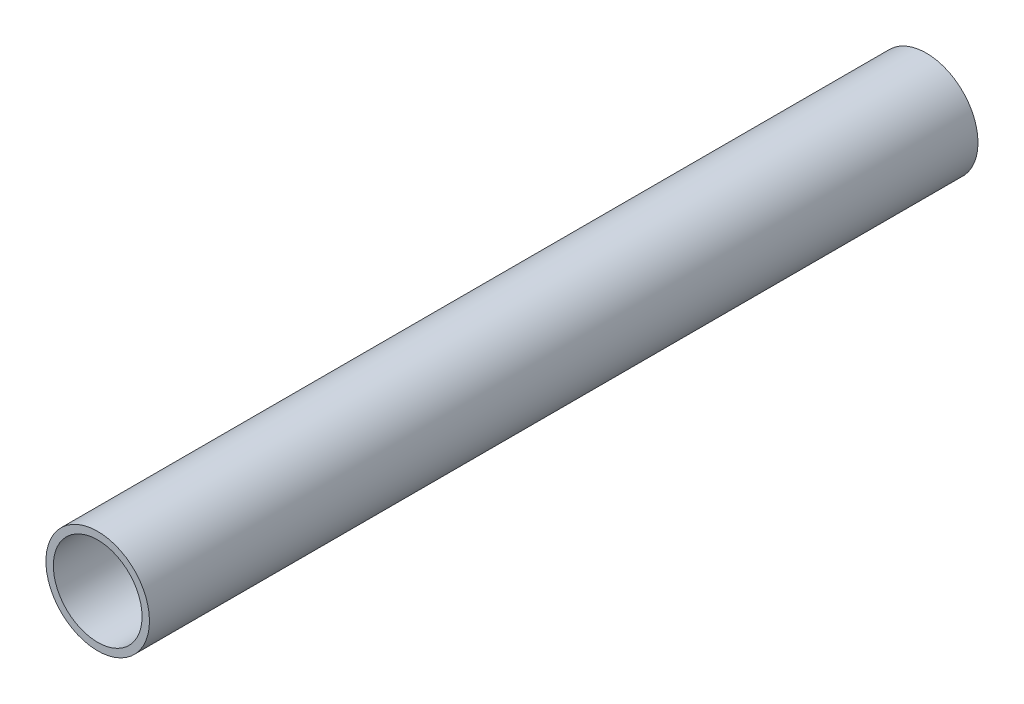
from build123d import *

# Parameters (mm, degrees)
SKETCH1_R           = 3.175
BOSS_EXTRUDE1_DEPTH = 50.8
SKETCH2_R           = 2.720195111
CUT_EXTRUDE1_DEPTH  = 50.8


with BuildPart() as part:
    # Sketch1 → Boss-Extrude1 (new body)
    with BuildSketch(Plane.XY):
        Circle(SKETCH1_R)
    extrude(amount=BOSS_EXTRUDE1_DEPTH)

    # Sketch2 → Cut-Extrude1 (cut)
    with BuildSketch(Plane.XY.offset(50.8)):
        Circle(SKETCH2_R)
    extrude(amount=-CUT_EXTRUDE1_DEPTH, mode=Mode.SUBTRACT)


solid = part.part
